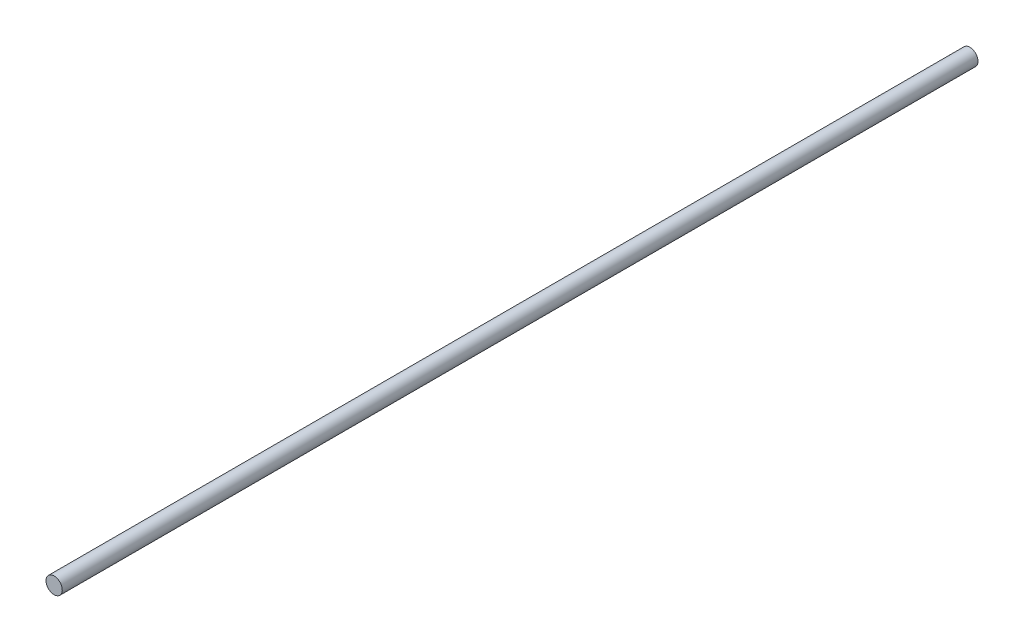
from build123d import *

# Parameters (mm, degrees)
SKETCH1_R           = 4
BOSS_EXTRUDE1_DEPTH = 450


with BuildPart() as part:
    # Sketch1 → Boss-Extrude1 (new body)
    with BuildSketch(Plane.XY):
        Circle(SKETCH1_R)
    extrude(amount=BOSS_EXTRUDE1_DEPTH)


solid = part.part
